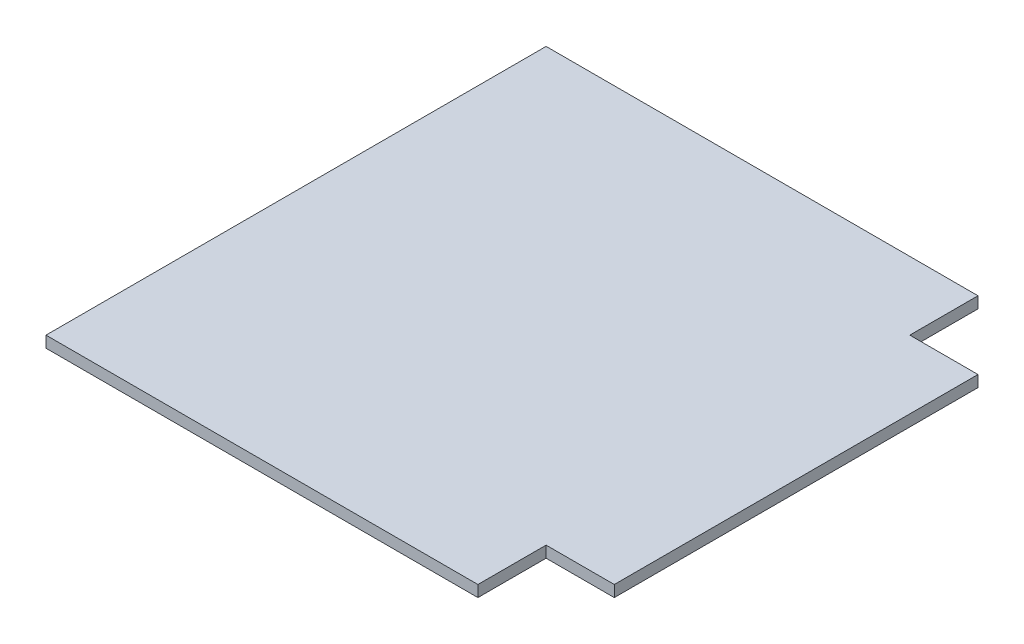
from build123d import *

# Parameters (mm, degrees)
CROQUIS1_W              = 279.4
CROQUIS1_H              = 279.4
SALIENTE_EXTRUIR1_DEPTH = 6.35
CROQUIS3_W              = 38.1
CROQUIS3_H              = 38.1
CORTAR_EXTRUIR1_DEPTH   = 7.35


with BuildPart() as part:
    # Croquis1 → Saliente-Extruir1 (new body)
    with BuildSketch(Plane(origin=(0, 0, 0), x_dir=(1, 0, 0), z_dir=(0, 1, 0))):
        Rectangle(CROQUIS1_W, CROQUIS1_H)
    extrude(amount=SALIENTE_EXTRUIR1_DEPTH)

    # Croquis3 → Cortar-Extruir1 (cut, through all)
    with BuildSketch(Plane(origin=(0, 6.35, 0), x_dir=(1, 0, 0), z_dir=(0, 1, 0))):
        with Locations((120.65, -120.65)):
            Rectangle(CROQUIS3_W, CROQUIS3_H)
        with Locations((120.65, 120.65)):
            Rectangle(CROQUIS3_W, CROQUIS3_H)
    extrude(amount=-CORTAR_EXTRUIR1_DEPTH, mode=Mode.SUBTRACT)


solid = part.part
